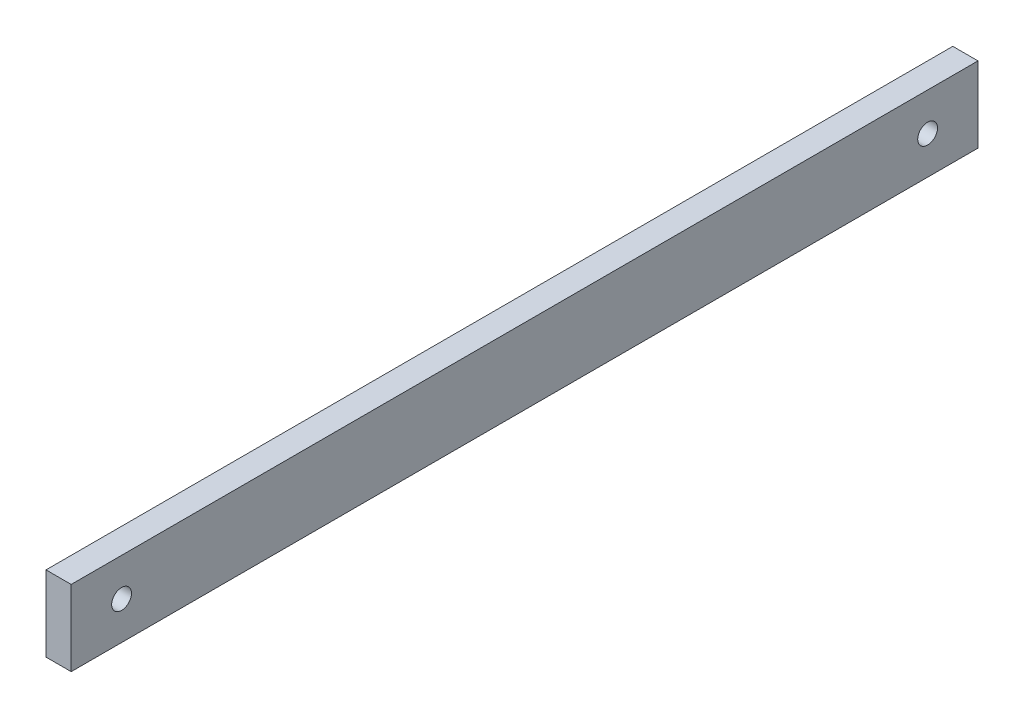
from build123d import *

# Parameters (mm, degrees)
SKETCH1_W                 = 6.35
SKETCH1_H                 = 19.05
EXTRUDE1_DEPTH            = 114.3
M6X1_0_TAPPED_HOLE1_D     = 5
M6X1_0_TAPPED_HOLE1_DEPTH = 6.35


with BuildPart() as part:
    # Sketch1 → Extrude1 (new body, symmetric)
    with BuildSketch(Plane.XY):
        Rectangle(SKETCH1_W, SKETCH1_H)
    extrude(amount=EXTRUDE1_DEPTH, both=True)

    # M6x1.0 Tapped Hole1
    with Locations(Plane(origin=(3.175, 0, 0), x_dir=(0, 0, -1), z_dir=(1, 0, 0))):
        with Locations((-101.6, 0), (101.6, 0)):
            Hole(M6X1_0_TAPPED_HOLE1_D / 2, depth=M6X1_0_TAPPED_HOLE1_DEPTH)


solid = part.part
